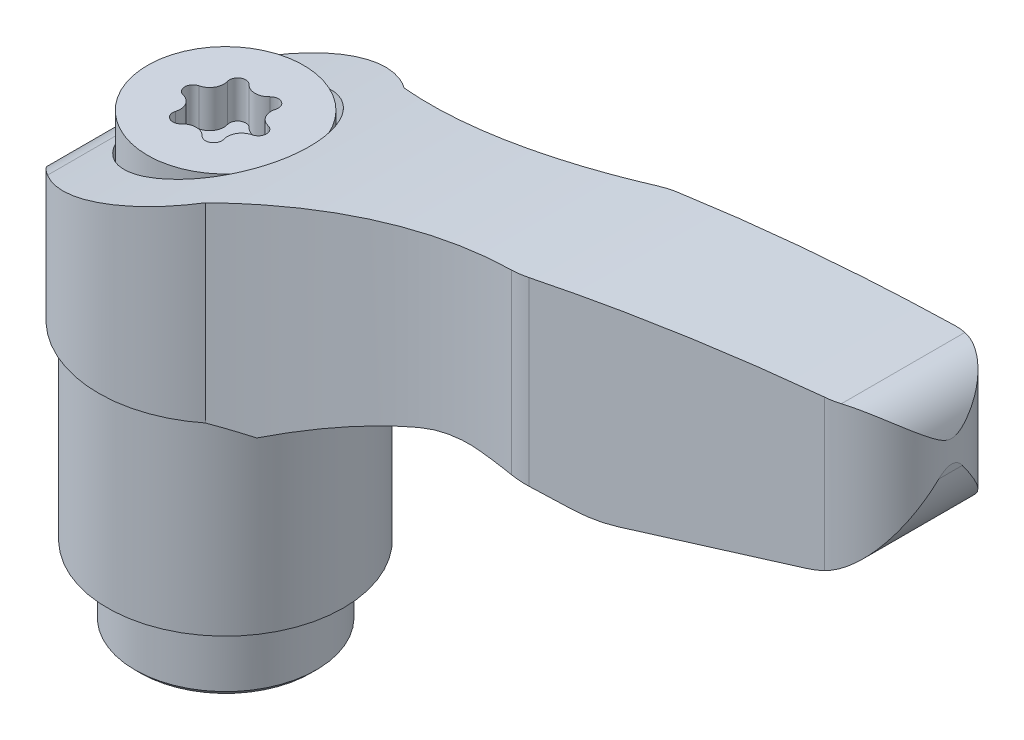
from build123d import *

# Parameters (mm, degrees)
EXTRUDE1_DEPTH      = 8
EXTRUDE1_DEPTH_BACK = 8
SKETCH2_W           = 6.5
SKETCH2_H           = 12.5625
SKETCH3_W           = 94
SKETCH3_H           = 94
EXTRUDE2_DEPTH      = 31
EXTRUDE3_DEPTH      = 14
EXTRUDE3_DEPTH_BACK = 14
SKETCH4_W           = 94
SKETCH4_H           = 47
EXTRUDE4_DEPTH      = 2.06
EXTRUDE4_DEPTH_BACK = 2.06


with BuildPart() as part:
    # Sketch1 → Extrude1 (new, two sides: drawn at the far end of the back side and taken through both)
    with BuildSketch(Plane.XY.offset(-EXTRUDE1_DEPTH_BACK)):
        with BuildLine():
            Line((-6.51, 14.5), (6.49, 14.5))
            ThreePointArc((6.49, 14.5), (10.317505243, 16.512584876), (14.256035557, 18.29815852))
            ThreePointArc((14.256035557, 18.29815852), (15.968337207, 18.822804929), (17.75042382, 19))
            Line((17.75042382, 19), (23.046668584, 19))
            ThreePointArc((23.046668584, 19), (24.290541726, 19.085889358), (25.51080482, 19.341927159))
            Line((25.51080482, 19.341927159), (35.534460964, 22.178335945))
            ThreePointArc((35.534460964, 22.178335945), (38.480369536, 24.039582758), (39.938965898, 27.204249197))
            Line((39.938965898, 27.204249197), (40.03902701, 27.893511518))
            ThreePointArc((40.03902701, 27.893511518), (39.384905735, 30.021406047), (37.324018346, 30.863161913))
            ThreePointArc((37.324018346, 30.863161913), (16.196447137, 28.065543342), (-4.25177913, 22.059631473))
            ThreePointArc((-4.25177913, 22.059631473), (-5.890644629, 20.775261015), (-6.51, 18.787325774))
            Line((-6.51, 18.787325774), (-6.51, 14.5))
        make_face()
    extrude(amount=EXTRUDE1_DEPTH + EXTRUDE1_DEPTH_BACK)

    # Sketch2 → Revolve1 (revolve)
    with BuildSketch(Plane.XY):
        with Locations((-3.26, 10.28125)):
            Rectangle(SKETCH2_W, SKETCH2_H)
    revolve(axis=Axis((-0.01, 16.5625, 0), (0, -1, 0)))

    # Sketch3 → Extrude2 (cut)
    with BuildSketch(Plane(origin=(0, 31, 0), x_dir=(-1, 0, 0), z_dir=(0, 1, 0))):
        with Locations((-7, -7)):
            Rectangle(SKETCH3_W, SKETCH3_H)
        with BuildLine():
            Line((-20.791020756, 4.081513031), (-36.5, 3.5))
            ThreePointArc((-36.5, 3.5), (-40, 0), (-36.5, -3.5))
            Line((-36.5, -3.5), (-20.791020756, -4.081513031))
            ThreePointArc((-20.791020756, -4.081513031), (-20.282143055, -4.074432197), (-19.7766212, -4.015658847))
            ThreePointArc((-19.7766212, -4.015658847), (-11.97399514, -3.733401658), (-4.362785826, -5.474130053))
            ThreePointArc((-4.362785826, -5.474130053), (7, 0), (-4.362785826, 5.474130053))
            ThreePointArc((-4.362785826, 5.474130053), (-11.97399514, 3.733401658), (-19.7766212, 4.015658847))
            ThreePointArc((-19.7766212, 4.015658847), (-20.282143055, 4.074432197), (-20.791020756, 4.081513031))
        make_face(mode=Mode.SUBTRACT)
    extrude(amount=-EXTRUDE2_DEPTH, mode=Mode.SUBTRACT)

    # Sketch4 → Extrude3 (cut, two sides: drawn at the far end of the back side and taken through both)
    with BuildSketch(Plane.XY.offset(-EXTRUDE3_DEPTH_BACK)):
        with Locations((7, 23.5)):
            Rectangle(SKETCH4_W, SKETCH4_H)
        with BuildLine():
            Line((-6.51, 18.787325774), (-6.51, 4.149977348))
            Line((-6.51, 4.149977348), (-6.360022652, 4))
            Line((-6.360022652, 4), (6.49, 4))
            Line((6.49, 4), (6.49, 9.643220966))
            ThreePointArc((6.49, 9.643220966), (7.726858035, 13.916382648), (11.05497769, 16.868220739))
            ThreePointArc((11.05497769, 16.868220739), (12.647037105, 17.602149488), (14.256035557, 18.29815852))
            ThreePointArc((14.256035557, 18.29815852), (15.968337207, 18.822804929), (17.75042382, 19))
            Line((17.75042382, 19), (23.046668584, 19))
            ThreePointArc((23.046668584, 19), (24.290541726, 19.085889358), (25.51080482, 19.341927159))
            Line((25.51080482, 19.341927159), (35.534460964, 22.178335945))
            ThreePointArc((35.534460964, 22.178335945), (38.480369536, 24.039582758), (39.938965898, 27.204249197))
            Line((39.938965898, 27.204249197), (40.03902701, 27.893511518))
            ThreePointArc((40.03902701, 27.893511518), (39.384905735, 30.021406047), (37.324018346, 30.863161913))
            ThreePointArc((37.324018346, 30.863161913), (16.196447137, 28.065543342), (-4.25177913, 22.059631473))
            ThreePointArc((-4.25177913, 22.059631473), (-5.890644629, 20.775261015), (-6.51, 18.787325774))
        make_face(mode=Mode.SUBTRACT)
    extrude(amount=EXTRUDE3_DEPTH + EXTRUDE3_DEPTH_BACK, mode=Mode.SUBTRACT)

    # Sketch5 → Cut-Revolve1 (revolve, cut)
    with BuildSketch(Plane.XY):
        Polygon((0, 28.5), (4.926418831, 28.5), (4.3, 21.34), (4.3, 16), (2.5, 16), (2.5, 15), (4.15, 15), (4.15, 12.8), (5, 12.8), (5, 4.55), (5.25, 4.3), (5.25, 3), (0, 3), align=None)
    revolve(axis=Axis((0, 4, 0), (0, 1, 0)), mode=Mode.SUBTRACT)

    # Sketch6 → Revolve2 (revolve)
    with BuildSketch(Plane.XY):
        Polygon((0, 24.5), (4.3, 24.5), (4.3, 21.339), (2.5, 21.339), (2.5, 15), (4.15, 15), (4.15, 12.8), (5, 12.8), (5, 0.3), (4.7, 0), (0, 0), align=None)
    revolve(axis=Axis((0, 0, 0), (0, 1, 0)))

    # Sketch7 → Extrude4 (cut, two sides: drawn at the far end of the back side and taken through both)
    with BuildSketch(Plane(origin=(0, 24.5, 0), x_dir=(-1, 0, 0), z_dir=(0, 1, 0)).offset(-EXTRUDE4_DEPTH_BACK)):
        with BuildLine():
            ThreePointArc((1.903841526, -0.437854927), (2.25, 0), (1.903841526, 0.437854927))
            ThreePointArc((1.903841526, 0.437854927), (1.403569191, 0.81035105), (1.331114253, 1.429847663))
            ThreePointArc((1.331114253, 1.429847663), (1.125, 1.948557159), (0.572727273, 1.86770259))
            ThreePointArc((0.572727273, 1.86770259), (0, 1.620702101), (-0.572727273, 1.86770259))
            ThreePointArc((-0.572727273, 1.86770259), (-1.125, 1.948557159), (-1.331114253, 1.429847663))
            ThreePointArc((-1.331114253, 1.429847663), (-1.403569191, 0.81035105), (-1.903841526, 0.437854927))
            ThreePointArc((-1.903841526, 0.437854927), (-2.25, 0), (-1.903841526, -0.437854927))
            ThreePointArc((-1.903841526, -0.437854927), (-1.403569191, -0.81035105), (-1.331114253, -1.429847663))
            ThreePointArc((-1.331114253, -1.429847663), (-1.125, -1.948557159), (-0.572727273, -1.86770259))
            ThreePointArc((-0.572727273, -1.86770259), (0, -1.620702101), (0.572727273, -1.86770259))
            ThreePointArc((0.572727273, -1.86770259), (1.125, -1.948557159), (1.331114253, -1.429847663))
            ThreePointArc((1.331114253, -1.429847663), (1.403569191, -0.81035105), (1.903841526, -0.437854927))
        make_face()
    extrude(amount=EXTRUDE4_DEPTH + EXTRUDE4_DEPTH_BACK, mode=Mode.SUBTRACT)

    # Sketch8 → Cut-Revolve2 (revolve, cut)
    with BuildSketch(Plane.XY):
        Polygon((0, 12.419415637), (2.4585, 11), (2.4585, 0.5415), (3, 0), (0, 0), align=None)
    revolve(axis=Axis((0, 0, 0), (0, 1, 0)), mode=Mode.SUBTRACT)


solid = part.part
